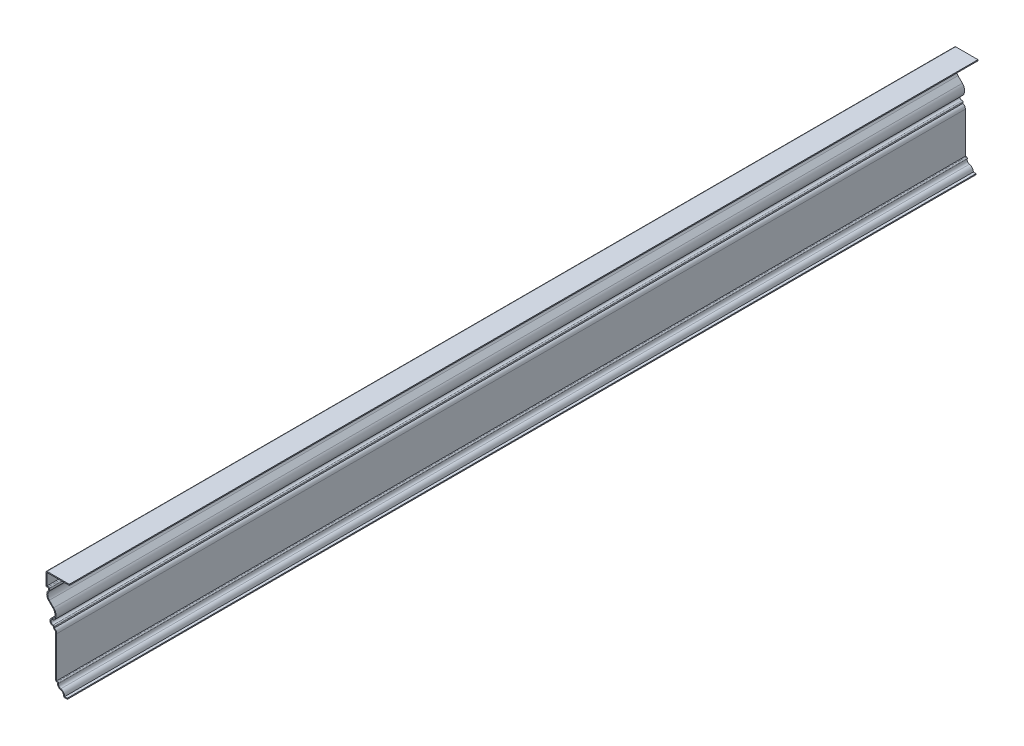
from build123d import *

# Parameters (mm, degrees)
EXTRUDE_THIN1_DEPTH = 1483.36
FILLET1_R           = 1.651


with BuildPart() as part:
    # Sketch1 → Extrude-Thin1 (new body)
    with BuildSketch(Plane.XY):
        with BuildLine():
            Line((0, 0), (-6.35, 0))
            ThreePointArc((-6.35, 0), (-7.014161405, 4.999003157), (-11.1125, 7.9375))
            ThreePointArc((-11.1125, 7.9375), (-15.210838595, 10.875996843), (-15.875, 15.875))
            Line((-15.875, 15.875), (-19.05, 15.875))
            Line((-19.05, 15.875), (-19.05, 84.1375))
            ThreePointArc((-19.05, 84.1375), (-20.172243592, 87.23719284), (-23.01875, 88.9))
            Line((-23.01875, 88.9), (-23.01875, 92.075))
            ThreePointArc((-23.01875, 92.075), (-28.575, 97.234375), (-23.01875, 102.39375))
            ThreePointArc((-23.01875, 102.39375), (-20.320127613, 109.826332694), (-23.453963425, 117.086148215))
            Line((-23.453963425, 117.086148215), (-30.595841102, 124.228025892))
            ThreePointArc((-30.595841102, 124.228025892), (-33.729676913, 131.487841413), (-31.031054527, 138.920424107))
            Line((-31.031054527, 138.920424107), (-31.031054527, 142.095424107))
            Line((-31.031054527, 142.095424107), (-34.925, 142.095424107))
            Line((-34.925, 142.095424107), (-34.925, 164.320424107))
            Line((-34.925, 164.320424107), (3.175, 164.320424107))
            Line((3.175, 164.320424107), (3.175, 162.669424107))
            Line((3.175, 162.669424107), (-33.274, 162.669424107))
            Line((-33.274, 162.669424107), (-33.274, 143.746424107))
            Line((-33.274, 143.746424107), (-29.380054527, 143.746424107))
            Line((-29.380054527, 143.746424107), (-29.380054527, 138.262766033))
            ThreePointArc((-29.380054527, 138.262766033), (-32.083310998, 131.839180164), (-29.428407806, 125.395459188))
            Line((-29.428407806, 125.395459188), (-22.286530129, 118.253581511))
            ThreePointArc((-22.286530129, 118.253581511), (-18.6648529, 109.406728179), (-22.4324376, 100.621020162))
            ThreePointArc((-22.4324376, 100.621020162), (-26.874175858, 96.64400772), (-21.36775, 94.35819474))
            Line((-21.36775, 94.35819474), (-21.36775, 90.119658369))
            ThreePointArc((-21.36775, 90.119658369), (-18.481410423, 87.72697055), (-17.399, 84.1375))
            Line((-17.399, 84.1375), (-17.399, 17.526))
            Line((-17.399, 17.526), (-13.027079679, 17.526))
            ThreePointArc((-13.027079679, 17.526), (-14.286028192, 12.859392651), (-10.762347214, 9.550941671))
            ThreePointArc((-10.762347214, 9.550941671), (-6.205237007, 6.722288668), (-4.45865105, 1.651))
            Line((-4.45865105, 1.651), (0, 1.651))
            Line((0, 1.651), (0, 0))
        make_face()
    extrude(amount=-EXTRUDE_THIN1_DEPTH)

    # Fillet1
    fillet1_edges = [part.edges().sort_by_distance(p)[0] for p in [
        (-29.380054527, 143.746424107, -741.68),
        (-29.380054527, 138.262766033, -741.68),
        (-22.4324376, 100.621020162, -741.68),
        (-21.36775, 94.35819474, -741.68),
        (-13.027079679, 17.526, -741.68),
        (-6.35, 0, -741.68),
        (-19.05, 15.875, -741.68),
        (-23.01875, 88.9, -741.68),
        (-34.925, 142.095424107, -741.68),
        (-34.925, 164.320424107, -741.68),
    ]]
    fillet(fillet1_edges, radius=FILLET1_R)


solid = part.part
